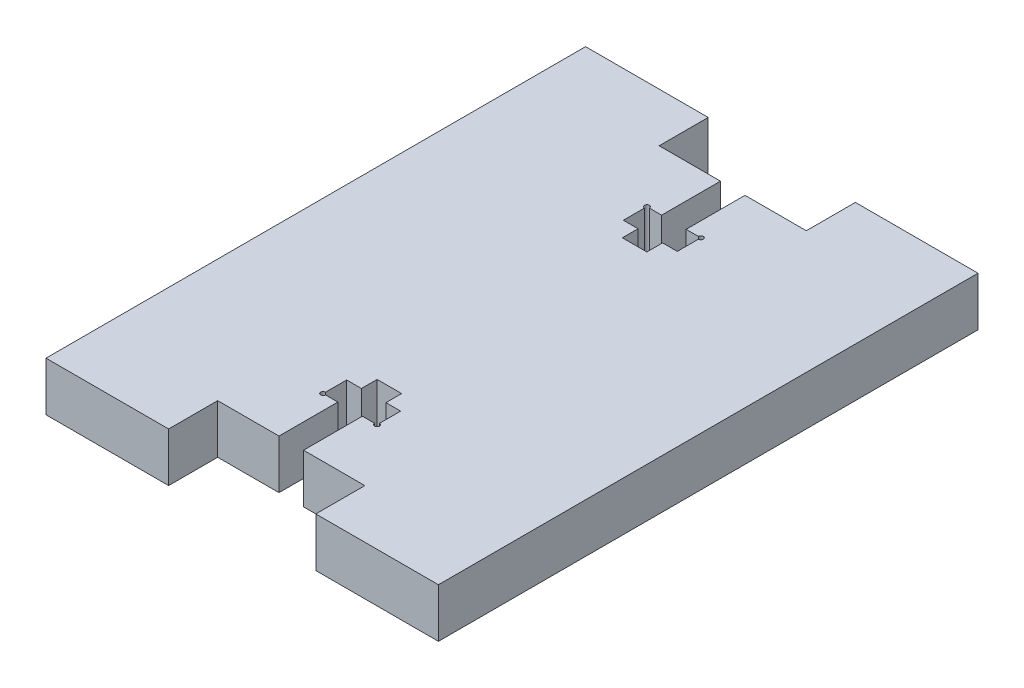
from build123d import *

# Parameters (mm, degrees)
SCHIZZO1_W                   = 40
SCHIZZO1_H                   = 55
ESTRUSIONE_ESTRUSIONE2_DEPTH = 5
SCHIZZO2_W                   = 15
SCHIZZO2_H                   = 5
TAGLIO_ESTRUSIONE1_DEPTH     = 6
TAGLIO_ESTRUSIONE3_DEPTH     = 6
SCHIZZO4_R                   = 0.25
TAGLIO_ESTRUSIONE4_DEPTH     = 10


with BuildPart() as part:
    # Schizzo1 → Estrusione-Estrusione2 (new body)
    with BuildSketch(Plane(origin=(0, 0, 0), x_dir=(1, 0, 0), z_dir=(0, 1, 0))):
        with Locations((-34.56494914, -0.781075862)):
            Rectangle(SCHIZZO1_W, SCHIZZO1_H)
    extrude(amount=-ESTRUSIONE_ESTRUSIONE2_DEPTH)

    # Schizzo2 → Taglio-Estrusione1 (cut, through all)
    with BuildSketch(Plane(origin=(0, 0, 0), x_dir=(1, 0, 0), z_dir=(0, 1, 0))):
        with Locations((-34.56494914, -25.781075862)):
            Rectangle(SCHIZZO2_W, SCHIZZO2_H)
        with Locations((-34.56494914, 24.218924138)):
            Rectangle(SCHIZZO2_W, SCHIZZO2_H)
    extrude(amount=-TAGLIO_ESTRUSIONE1_DEPTH, mode=Mode.SUBTRACT)

    # Schizzo3 → Taglio-Estrusione3 (cut, through all)
    with BuildSketch(Plane(origin=(0, 0, 0), x_dir=(1, 0, 0), z_dir=(0, 1, 0))):
        Polygon((-35.81494914, -23.281075862), (-33.31494914, -23.281075862), (-33.31494914, -17.281075862), (-31.81494914, -17.281075862), (-31.81494914, -14.881075862), (-33.31494914, -14.881075862), (-33.31494914, -13.281075862), (-35.81494914, -13.281075862), (-35.81494914, -14.881075862), (-37.31494914, -14.881075862), (-37.31494914, -17.281075862), (-35.81494914, -17.281075862), align=None)
        Polygon((-35.81494914, 11.718924138), (-33.31494914, 11.718924138), (-33.31494914, 13.318924138), (-31.81494914, 13.318924138), (-31.81494914, 15.718924138), (-33.31494914, 15.718924138), (-33.31494914, 21.718924138), (-35.81494914, 21.718924138), (-35.81494914, 15.718924138), (-37.31494914, 15.718924138), (-37.31494914, 13.318924138), (-35.81494914, 13.318924138), align=None)
    extrude(amount=-TAGLIO_ESTRUSIONE3_DEPTH, mode=Mode.SUBTRACT)

    # Schizzo4 → Taglio-Estrusione4 (cut)
    with BuildSketch(Plane(origin=(0, 0, 0), x_dir=(1, 0, 0), z_dir=(0, 1, 0))):
        with Locations((-37.31494914, -17.281075862)):
            Circle(SCHIZZO4_R)
        with Locations((-31.81494914, -17.281075862)):
            Circle(SCHIZZO4_R)
        with Locations((-37.31494914, 15.718924138)):
            Circle(SCHIZZO4_R)
        with Locations((-31.81494914, 15.718924138)):
            Circle(SCHIZZO4_R)
    extrude(amount=-TAGLIO_ESTRUSIONE4_DEPTH, mode=Mode.SUBTRACT)


solid = part.part
